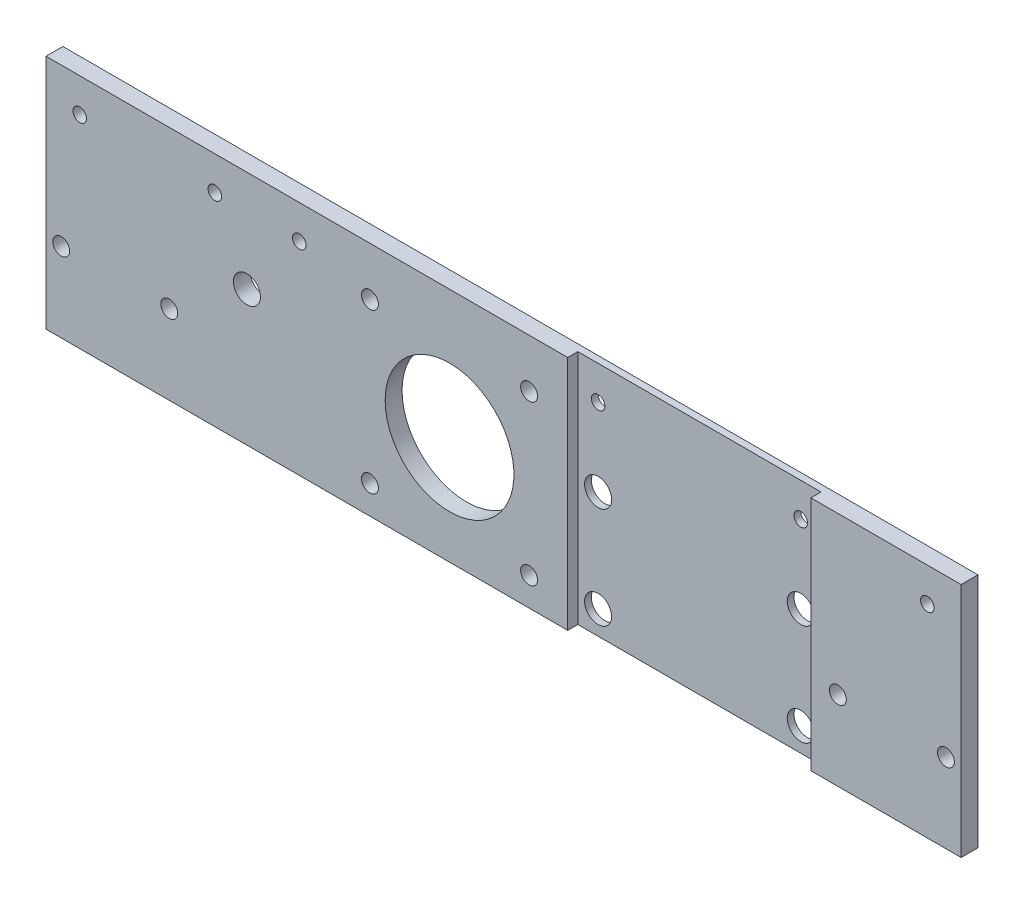
from build123d import *

# Parameters (mm, degrees)
SKIZZE1_W                       = 271
SKIZZE1_H                       = 70
AUFSATZ_LINEAR_AUSTRAGEN1_DEPTH = 5
SKIZZE2_W                       = 72
SKIZZE2_H                       = 70
SCHNITT_LINEAR_AUSTRAGEN1_DEPTH = 3
SKIZZE3_R                       = 4
SCHNITT_LINEAR_AUSTRAGEN2_DEPTH = 10
SKIZZE4_R                       = 2.5
SCHNITT_LINEAR_AUSTRAGEN3_DEPTH = 10
SKIZZE5_R                       = 2.5
SCHNITT_LINEAR_AUSTRAGEN4_DEPTH = 10
SKIZZE6_R                       = 2
SCHNITT_LINEAR_AUSTRAGEN5_DEPTH = 10
SKIZZE7_R                       = 19.0625
SKIZZE7_R_2                     = 2.5
SCHNITT_LINEAR_AUSTRAGEN6_DEPTH = 10
SKIZZE8_R                       = 4
SCHNITT_LINEAR_AUSTRAGEN7_DEPTH = 10
SKIZZE9_R                       = 2
SCHNITT_LINEAR_AUSTRAGEN8_DEPTH = 10


with BuildPart() as part:
    # Skizze1 → Aufsatz-Linear austragen1 (new body)
    with BuildSketch(Plane.XY):
        with Locations((135.5, 35)):
            Rectangle(SKIZZE1_W, SKIZZE1_H)
    extrude(amount=AUFSATZ_LINEAR_AUSTRAGEN1_DEPTH)

    # Skizze2 → Schnitt-Linear austragen1 (cut)
    with BuildSketch(Plane.XY.offset(5)):
        with Locations((190.5, 35)):
            Rectangle(SKIZZE2_W, SKIZZE2_H)
    extrude(amount=-SCHNITT_LINEAR_AUSTRAGEN1_DEPTH, mode=Mode.SUBTRACT)

    # Skizze3 → Schnitt-Linear austragen2 (cut)
    with BuildSketch(Plane(origin=(0, 0, 0), x_dir=(-1, 0, 0), z_dir=(0, 0, -1))):
        with Locations((-160.5, 37)):
            Circle(SKIZZE3_R)
        with Locations((-220.5, 37)):
            Circle(SKIZZE3_R)
        with Locations((-220.5, 7)):
            Circle(SKIZZE3_R)
        with Locations((-160.5, 7)):
            Circle(SKIZZE3_R)
    extrude(amount=-SCHNITT_LINEAR_AUSTRAGEN2_DEPTH, mode=Mode.SUBTRACT)

    # Skizze4 → Schnitt-Linear austragen3 (cut)
    with BuildSketch(Plane(origin=(0, 0, 0), x_dir=(-1, 0, 0), z_dir=(0, 0, -1))):
        with Locations((-234.5, 23.5)):
            Circle(SKIZZE4_R)
        with Locations((-266.5, 23.5)):
            Circle(SKIZZE4_R)
    extrude(amount=-SCHNITT_LINEAR_AUSTRAGEN3_DEPTH, mode=Mode.SUBTRACT)

    # Skizze5 → Schnitt-Linear austragen4 (cut)
    with BuildSketch(Plane(origin=(0, 0, 0), x_dir=(-1, 0, 0), z_dir=(0, 0, -1))):
        with Locations((-36.5, 23.5)):
            Circle(SKIZZE5_R)
        with Locations((-4.5, 23.5)):
            Circle(SKIZZE5_R)
    extrude(amount=-SCHNITT_LINEAR_AUSTRAGEN4_DEPTH, mode=Mode.SUBTRACT)

    # Skizze6 → Schnitt-Linear austragen5 (cut)
    with BuildSketch(Plane(origin=(0, 0, 0), x_dir=(-1, 0, 0), z_dir=(0, 0, -1))):
        with Locations((-10, 60)):
            Circle(SKIZZE6_R)
        with Locations((-50, 60)):
            Circle(SKIZZE6_R)
        with Locations((-160.5, 60)):
            Circle(SKIZZE6_R)
        with Locations((-220.5, 60)):
            Circle(SKIZZE6_R)
        with Locations((-261, 60)):
            Circle(SKIZZE6_R)
    extrude(amount=-SCHNITT_LINEAR_AUSTRAGEN5_DEPTH, mode=Mode.SUBTRACT)

    # Skizze7 → Schnitt-Linear austragen6 (cut)
    with BuildSketch(Plane(origin=(0, 0, 0), x_dir=(-1, 0, 0), z_dir=(0, 0, -1))):
        with Locations((-119.5, 32)):
            Circle(SKIZZE7_R)
        with Locations((-95.93, 8.43)):
            Circle(SKIZZE7_R_2)
        with Locations((-143.07, 8.43)):
            Circle(SKIZZE7_R_2)
        with Locations((-95.93, 55.57)):
            Circle(SKIZZE7_R_2)
        with Locations((-143.07, 55.57)):
            Circle(SKIZZE7_R_2)
    extrude(amount=-SCHNITT_LINEAR_AUSTRAGEN6_DEPTH, mode=Mode.SUBTRACT)

    # Skizze8 → Schnitt-Linear austragen7 (cut)
    with BuildSketch(Plane(origin=(0, 0, 0), x_dir=(-1, 0, 0), z_dir=(0, 0, -1))):
        with Locations((-59.5, 40)):
            Circle(SKIZZE8_R)
    extrude(amount=-SCHNITT_LINEAR_AUSTRAGEN7_DEPTH, mode=Mode.SUBTRACT)

    # Skizze9 → Schnitt-Linear austragen8 (cut)
    with BuildSketch(Plane.XY.offset(5)):
        with Locations((75, 60)):
            Circle(SKIZZE9_R)
    extrude(amount=-SCHNITT_LINEAR_AUSTRAGEN8_DEPTH, mode=Mode.SUBTRACT)


solid = part.part
